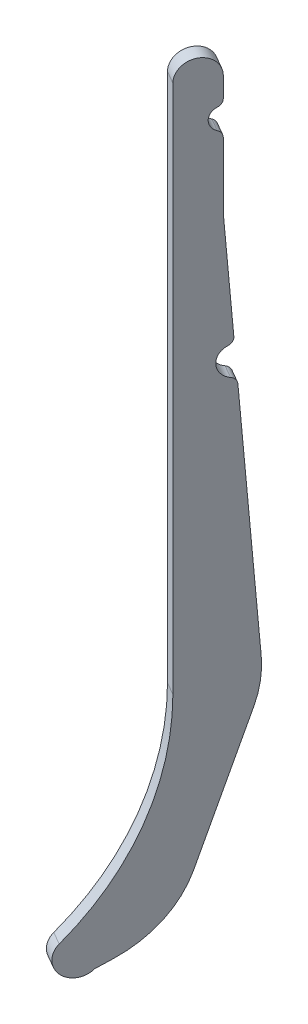
from build123d import *

# Parameters (mm, degrees)
BOSS_EXTRUDE1_DEPTH = 4


with BuildPart() as part:
    # Sketch1 → Boss-Extrude1 (new body)
    with BuildSketch(Plane(origin=(-22.684789061, 0, -13.097069071), x_dir=(-0.5, 0, 0.866025404), z_dir=(-0.866025404, 0, -0.5))):
        with BuildLine():
            Line((-51.22508588, -207.116263928), (-51.22508588, -63.668461088))
            ThreePointArc((-51.22508588, -63.668461088), (-56.22508588, -58.668461088), (-61.22508588, -63.668461088))
            Line((-61.22508588, -63.668461088), (-61.22508588, -69.085885393))
            ThreePointArc((-61.22508588, -69.085885393), (-60.898405933, -70.181330508), (-60.02508588, -70.918915671))
            ThreePointArc((-60.02508588, -70.918915671), (-58.22508588, -73.668461088), (-60.02508588, -76.418006505))
            ThreePointArc((-60.02508588, -76.418006505), (-60.898405933, -77.155591668), (-61.22508588, -78.251036783))
            Line((-61.22508588, -78.251036783), (-61.22508588, -96.050188948))
            Line((-61.22508588, -96.050188948), (-63.318074095, -125.318595172))
            ThreePointArc((-63.318074095, -125.318595172), (-63.034364548, -126.496532456), (-62.122634264, -127.294514437))
            ThreePointArc((-62.122634264, -127.294514437), (-59.731754601, -131.246352968), (-62.660623811, -134.817775441))
            ThreePointArc((-62.660623811, -134.817775441), (-63.676623884, -135.477905129), (-64.125058417, -136.603486678))
            Line((-64.125058417, -136.603486678), (-68.745111695, -201.210442006))
            ThreePointArc((-68.745111695, -201.210442006), (-68.593140236, -207.044992568), (-67.314310613, -212.739698038))
            Line((-67.314310613, -212.739698038), (-55.328501922, -249.111405981))
            ThreePointArc((-55.328501922, -249.111405981), (-49.184106644, -259.735720996), (-39.299344022, -267.010412109))
            Line((-39.299344022, -267.010412109), (-35.743375843, -268.634553892))
            ThreePointArc((-35.743375843, -268.634553892), (-28.672308031, -268.634553892), (-28.672308031, -261.56348608))
            ThreePointArc((-28.672308031, -261.56348608), (-45.363809883, -236.582888221), (-51.22508588, -207.116263928))
        make_face()
    extrude(amount=BOSS_EXTRUDE1_DEPTH)


solid = part.part
